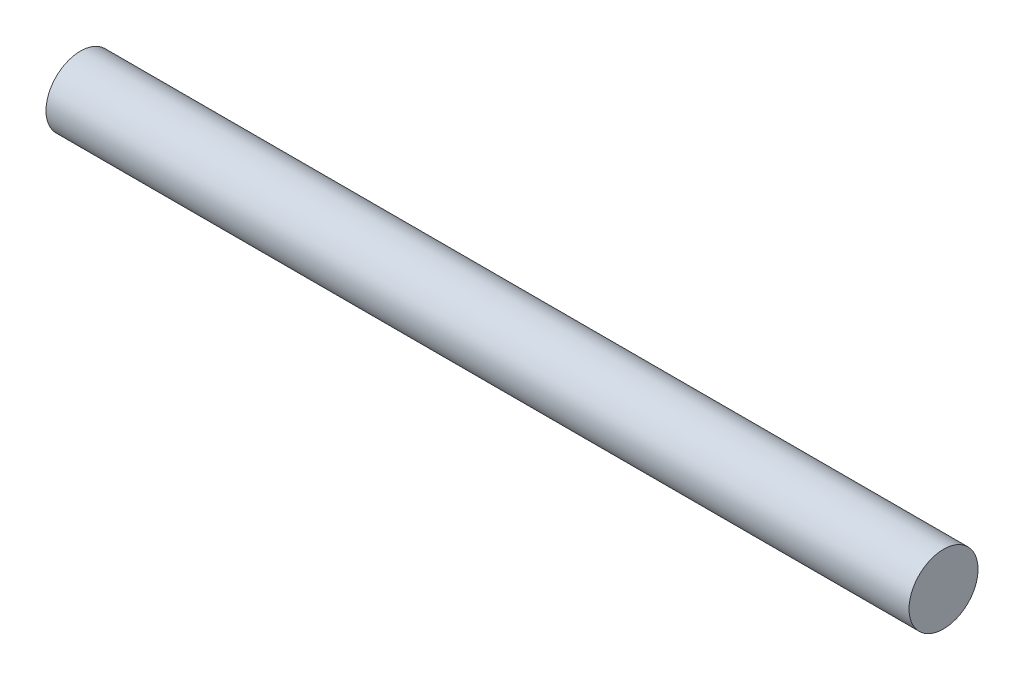
from build123d import *

# Parameters (mm, degrees)
ESQUISSE1_W = 100
ESQUISSE1_H = 4


with BuildPart() as part:
    # Esquisse1 → Révolution1 (revolve)
    with BuildSketch(Plane.XY):
        with Locations((50, 2)):
            Rectangle(ESQUISSE1_W, ESQUISSE1_H)
    revolve(axis=Axis((0, 0, 0), (1, 0, 0)))


solid = part.part
